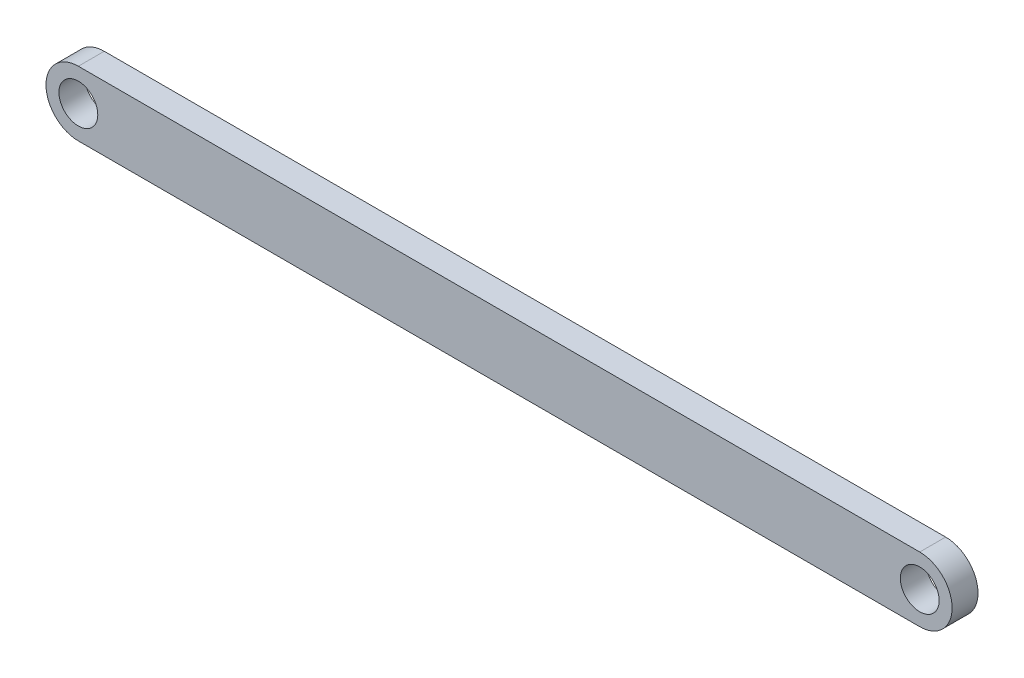
from build123d import *

# Parameters (mm, degrees)
SKETCH1_R           = 1.5
BOSS_EXTRUDE1_DEPTH = 2


with BuildPart() as part:
    # Sketch1 → Boss-Extrude1 (new body)
    with BuildSketch(Plane.XY):
        with BuildLine():
            Line((0, -2.5), (-65, -2.5))
            ThreePointArc((-65, -2.5), (-67.5, 0), (-65, 2.5))
            Line((-65, 2.5), (0, 2.5))
            ThreePointArc((0, 2.5), (2.5, 0), (0, -2.5))
        make_face()
        with Locations((-65, 0)):
            Circle(SKETCH1_R, mode=Mode.SUBTRACT)
        Circle(SKETCH1_R, mode=Mode.SUBTRACT)
    extrude(amount=BOSS_EXTRUDE1_DEPTH)


solid = part.part
